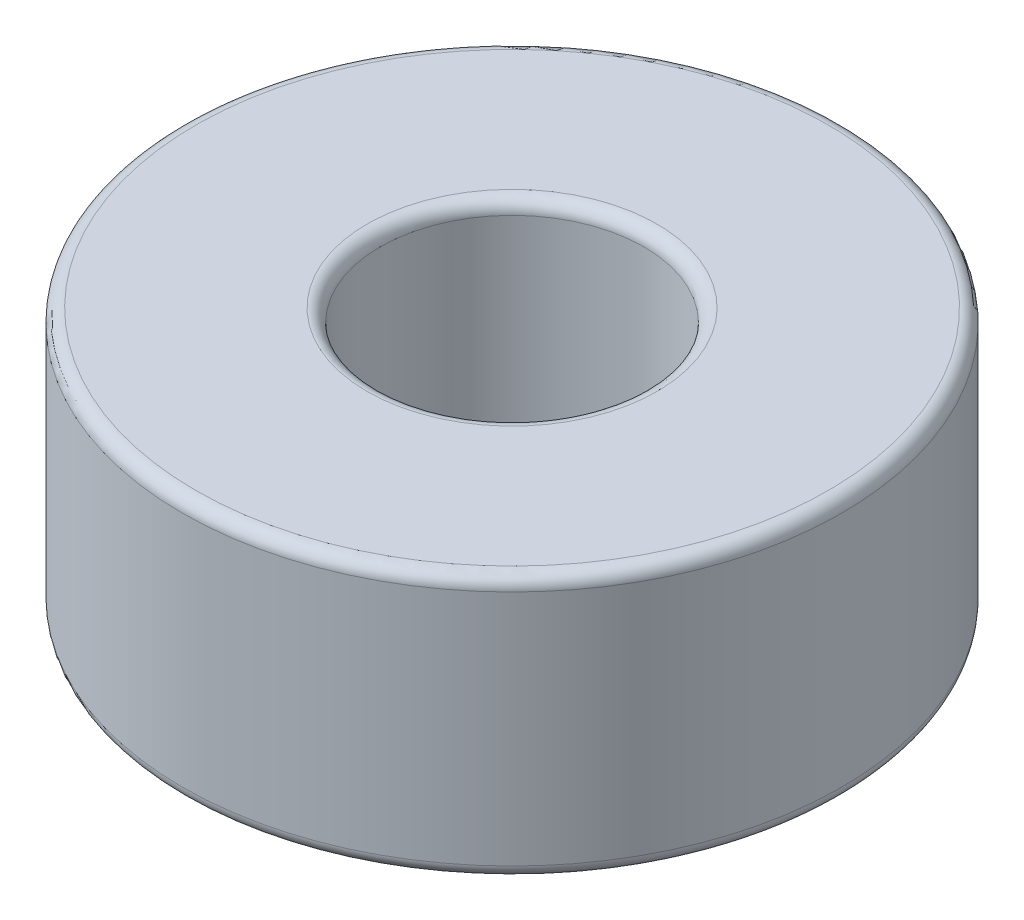
from build123d import *

# Parameters (mm, degrees)
SKETCH1_R           = 7.5
SKETCH1_R_2         = 3
BOSS_EXTRUDE1_DEPTH = 3
FILLET1_R           = 0.3


with BuildPart() as part:
    # Sketch1 → Boss-Extrude1 (new body, symmetric)
    with BuildSketch(Plane(origin=(0, 0, 0), x_dir=(1, 0, 0), z_dir=(0, 1, 0))):
        Circle(SKETCH1_R)
        Circle(SKETCH1_R_2, mode=Mode.SUBTRACT)
    extrude(amount=BOSS_EXTRUDE1_DEPTH, both=True)

    # Fillet1
    fillet1_edges = [part.edges().sort_by_distance(p)[0] for p in [
        (-7.5, -3, 0),
        (-7.5, 3, 0),
        (-3, -3, 0),
        (-3, 3, 0),
    ]]
    fillet(fillet1_edges, radius=FILLET1_R)


solid = part.part
